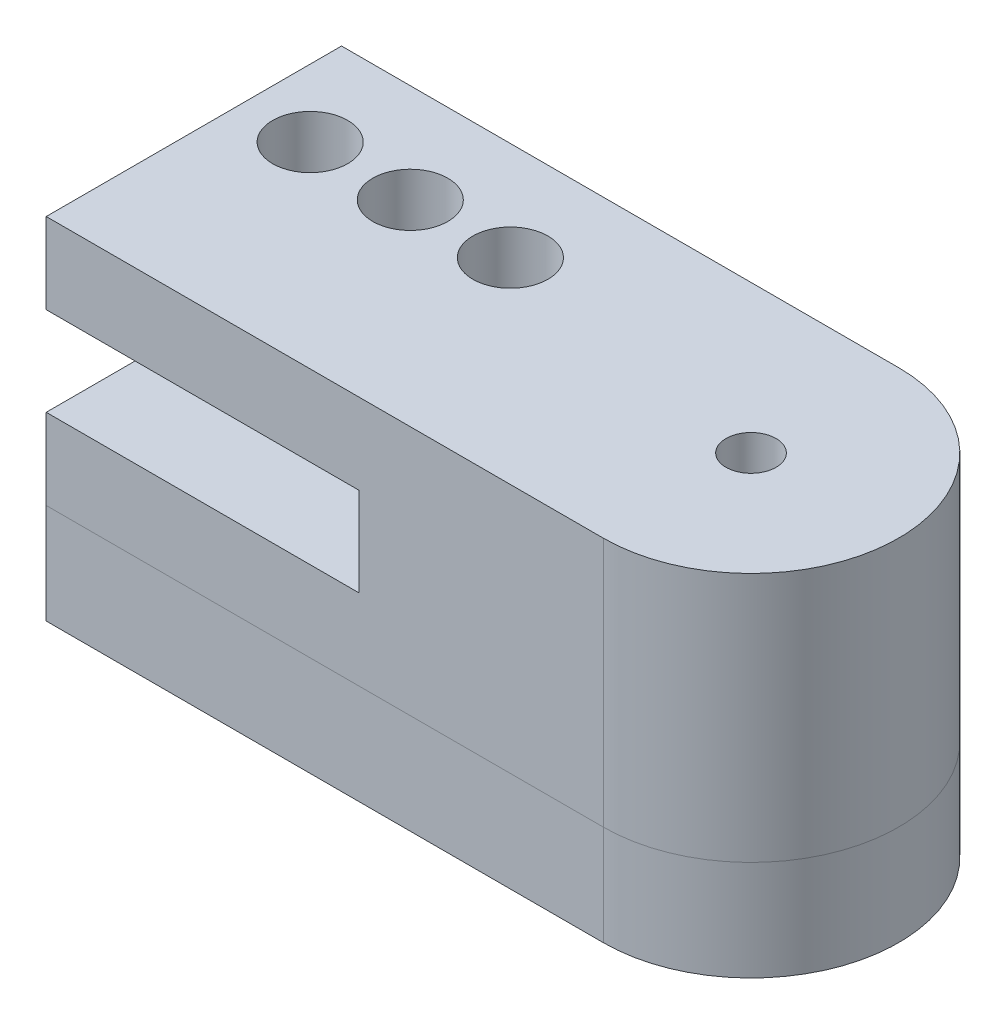
from build123d import *

# Parameters (mm, degrees)
BOSS_EXTRUDE2_DEPTH = 10
BOSS_EXTRUDE3_DEPTH = 4
CUT_EXTRUDE1_DEPTH  = 4
SKETCH7_R           = 1
CUT_EXTRUDE2_DEPTH  = 11
SKETCH9_W           = 12.5
SKETCH9_H           = 3.55
CUT_EXTRUDE7_DEPTH  = 12.800523878
SKETCH11_R          = 1.5
CUT_EXTRUDE8_DEPTH  = 15


with BuildPart() as part:
    # Sketch1 → Boss-Extrude2 (new body)
    with BuildSketch(Plane(origin=(0, 0, 0), x_dir=(1, 0, 0), z_dir=(0, 1, 0))):
        with BuildLine():
            Line((19.837809991, 13.8), (19.837809991, 1.999476122))
            Line((19.837809991, 1.999476122), (42.1, 1.999476122))
            ThreePointArc((42.1, 1.999476122), (48.000261939, 7.899738061), (42.1, 13.8))
            Line((42.1, 13.8), (19.837809991, 13.8))
        make_face()
    extrude(amount=BOSS_EXTRUDE2_DEPTH)

    # Sketch4 → Boss-Extrude3 (add)
    with BuildSketch(Plane(origin=(0, 0, 0), x_dir=(-1, 0, 0), z_dir=(0, -1, 0))):
        with BuildLine():
            Line((-19.837809991, 2), (-19.837809991, 13.8))
            Line((-19.837809991, 13.8), (-42.1, 13.8))
            ThreePointArc((-42.1, 13.8), (-48, 7.9), (-42.1, 2))
            Line((-42.1, 2), (-19.837809991, 2))
        make_face()
    extrude(amount=BOSS_EXTRUDE3_DEPTH)

    # Sketch6 → Cut-Extrude1 (cut)
    with BuildSketch(Plane.XZ.offset(4)):
        with BuildLine():
            Line((28.779938833, -2.819139544), (40.580172538, -4.504631907))
            ThreePointArc((40.580172538, -4.504631907), (45.727347719, -8.725074859), (39.261067618, -10.303926565))
            Line((39.261067618, -10.303926565), (27.892761565, -6.719513435))
            ThreePointArc((27.892761565, -6.719513435), (26.386163253, -4.325737856), (28.779938833, -2.819139544))
        make_face()
    extrude(amount=-CUT_EXTRUDE1_DEPTH, mode=Mode.SUBTRACT)

    # Sketch7 → Cut-Extrude2 (cut, through all)
    with BuildSketch(Plane.XZ):
        with Locations((42.1, -7.9)):
            Circle(SKETCH7_R)
    extrude(amount=-CUT_EXTRUDE2_DEPTH, mode=Mode.SUBTRACT)

    # Sketch9 → Cut-Extrude7 (cut, through all)
    with BuildSketch(Plane.XY.offset(-1.999476122)):
        with Locations((26.087809991, 5)):
            Rectangle(SKETCH9_W, SKETCH9_H)
    extrude(amount=-CUT_EXTRUDE7_DEPTH, mode=Mode.SUBTRACT)

    # Sketch11 → Cut-Extrude8 (cut, through all)
    with BuildSketch(Plane(origin=(0, 10, 0), x_dir=(1, 0, 0), z_dir=(0, 1, 0))):
        with Locations((30.53490887, 9.85)):
            Circle(SKETCH11_R)
        with Locations((26.53490887, 9.85)):
            Circle(SKETCH11_R)
        with Locations((22.53490887, 9.85)):
            Circle(SKETCH11_R)
    extrude(amount=-CUT_EXTRUDE8_DEPTH, mode=Mode.SUBTRACT)


solid = part.part
